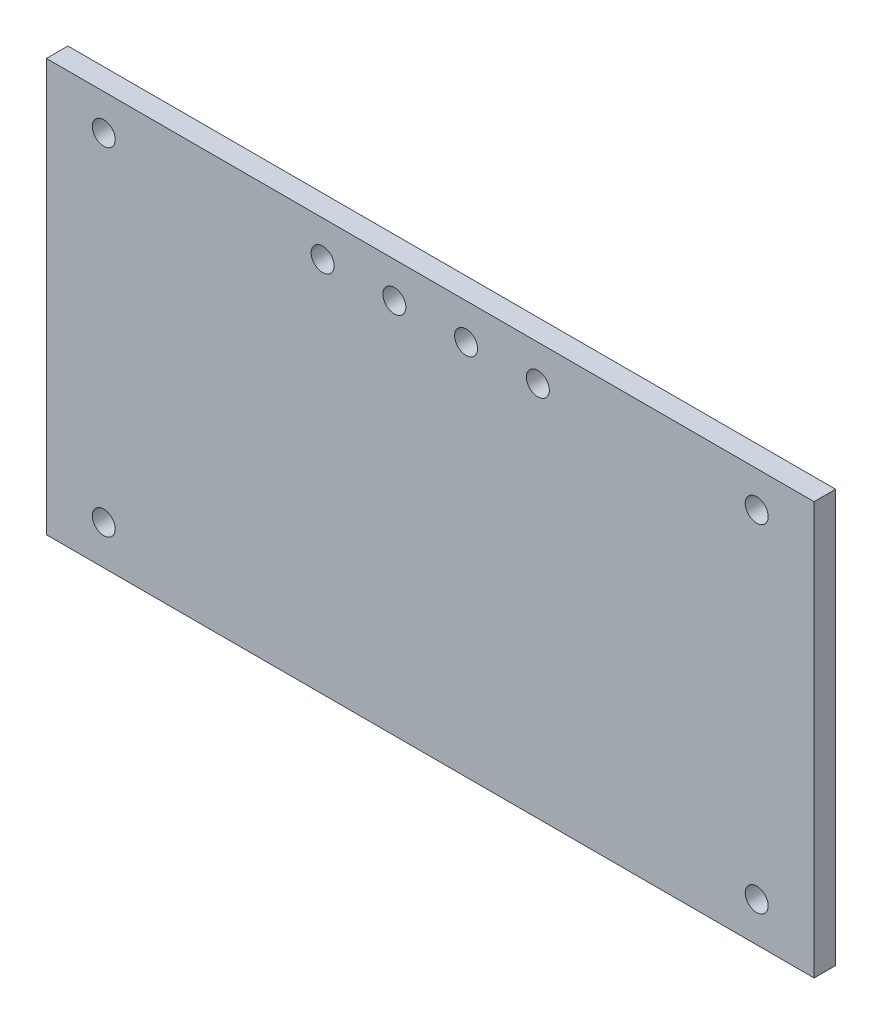
from build123d import *

# Parameters (mm, degrees)
SKETCH_1_W      = 107
SKETCH_1_H      = 57.495660379
SKETCH_1_R      = 1.6
EXTRUDE_1_DEPTH = 3


with BuildPart() as part:
    # 草图1 → 凸台-拉伸1 (new body)
    with BuildSketch(Plane.XY):
        with Locations((29.575989426, 3.082887299)):
            Rectangle(SKETCH_1_W, SKETCH_1_H)
        with Locations((-15.924010574, 26.830717489)):
            Circle(SKETCH_1_R, mode=Mode.SUBTRACT)
        with Locations((-15.924010574, -20.169282511)):
            Circle(SKETCH_1_R, mode=Mode.SUBTRACT)
        with Locations((75.075989426, -20.169282511)):
            Circle(SKETCH_1_R, mode=Mode.SUBTRACT)
        with Locations((75.075989426, 26.830717489)):
            Circle(SKETCH_1_R, mode=Mode.SUBTRACT)
        with Locations((14.575989426, 26.830717489)):
            Circle(SKETCH_1_R, mode=Mode.SUBTRACT)
        with Locations((24.575989426, 26.830717489)):
            Circle(SKETCH_1_R, mode=Mode.SUBTRACT)
        with Locations((34.575989426, 26.830717489)):
            Circle(SKETCH_1_R, mode=Mode.SUBTRACT)
        with Locations((44.575989426, 26.830717489)):
            Circle(SKETCH_1_R, mode=Mode.SUBTRACT)
    extrude(amount=EXTRUDE_1_DEPTH)


solid = part.part
